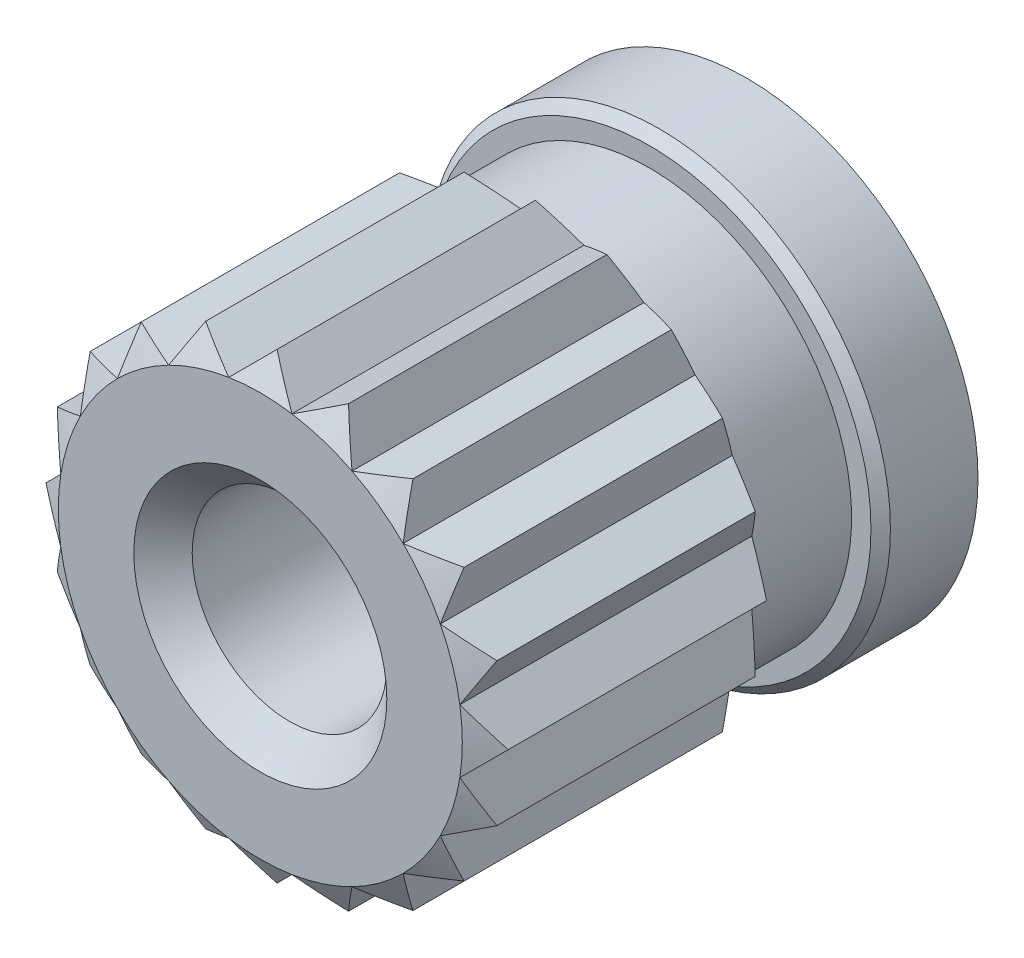
from build123d import *

# Parameters (mm, degrees)
BOSS_EXTRUDE1_DEPTH = 1.5
SKETCH2_OUTSIDE_W   = 18.614
SKETCH2_OUTSIDE_H   = 18.614
SKETCH2_OUTSIDE_R   = 2.075826116
CUT_EXTRUDE1_DEPTH  = 3
CUT_EXTRUDE1_TAPER  = 60
SKETCH3_R           = 2.375
BOSS_EXTRUDE2_DEPTH = 2
CUT_EXTRUDE3_START  = -1
SKETCH5_OUTSIDE_W   = 8.424
SKETCH5_OUTSIDE_H   = 8.424
SKETCH5_OUTSIDE_R   = 2.075826116
CUT_EXTRUDE3_DEPTH  = 1
CHAMFER1_SIZE       = 0.1
SKETCH6_R           = 1
CUT_EXTRUDE4_DEPTH  = 4
CHAMFER2_SIZE       = 0.3


with BuildPart() as part:
    # Sketch1 → Boss-Extrude1 (new body, symmetric)
    with BuildSketch(Plane.XY):
        Polygon((-0.324730748, 2.050269252), (0, 2.375), (0.324730748, 2.050269252), (0.733915362, 2.258759226), (0.942405336, 1.849574613), (1.395989974, 1.921415362), (1.467830723, 1.467830723), (1.921415362, 1.395989974), (1.849574613, 0.942405336), (2.258759226, 0.733915362), (2.050269252, 0.324730748), (2.375, 0), (2.050269252, -0.324730748), (2.258759226, -0.733915362), (1.849574613, -0.942405336), (1.921415362, -1.395989974), (1.467830723, -1.467830723), (1.395989974, -1.921415362), (0.942405336, -1.849574613), (0.733915362, -2.258759226), (0.324730748, -2.050269252), (0, -2.375), (-0.324730748, -2.050269252), (-0.733915362, -2.258759226), (-0.942405336, -1.849574613), (-1.395989974, -1.921415362), (-1.467830723, -1.467830723), (-1.921415362, -1.395989974), (-1.849574613, -0.942405336), (-2.258759226, -0.733915362), (-2.050269252, -0.324730748), (-2.375, 0), (-2.050269252, 0.324730748), (-2.258759226, 0.733915362), (-1.849574613, 0.942405336), (-1.921415362, 1.395989974), (-1.467830723, 1.467830723), (-1.395989974, 1.921415362), (-0.942405336, 1.849574613), (-0.733915362, 2.258759226), align=None)
    extrude(amount=BOSS_EXTRUDE1_DEPTH, both=True)

    # Sketch2 outside → Cut-Extrude1 (cut)
    with BuildSketch(Plane.XY.offset(1.5)):
        Rectangle(SKETCH2_OUTSIDE_W, SKETCH2_OUTSIDE_H)
        Circle(SKETCH2_OUTSIDE_R, mode=Mode.SUBTRACT)
    cut_extrude1 = extrude(amount=-CUT_EXTRUDE1_DEPTH, taper=CUT_EXTRUDE1_TAPER, mode=Mode.SUBTRACT)

    # Mirror1: Cut-Extrude1 across plane
    add(cut_extrude1.mirror(Plane.XY), mode=Mode.SUBTRACT)

    # Sketch3 → Boss-Extrude2 (add)
    with BuildSketch(Plane(origin=(0, 0, -1.5), x_dir=(-1, 0, 0), z_dir=(0, 0, -1))):
        Circle(SKETCH3_R)
    extrude(amount=BOSS_EXTRUDE2_DEPTH)

    # Sketch5 outside → Cut-Extrude3 (cut)
    with BuildSketch(Plane(origin=(0, 0, -3.5), x_dir=(-1, 0, 0), z_dir=(0, 0, -1)).offset(CUT_EXTRUDE3_START)):
        Rectangle(SKETCH5_OUTSIDE_W, SKETCH5_OUTSIDE_H)
        Circle(SKETCH5_OUTSIDE_R, mode=Mode.SUBTRACT)
    extrude(amount=-CUT_EXTRUDE3_DEPTH, mode=Mode.SUBTRACT)

    # Chamfer1
    chamfer1_edges = [part.edges().sort_by_distance(p)[0] for p in [
        (2.375, 0, -2.5),
    ]]
    chamfer(chamfer1_edges, length=CHAMFER1_SIZE)

    # Sketch6 → Cut-Extrude4 (cut)
    with BuildSketch(Plane.XY.offset(1.5)):
        Circle(SKETCH6_R)
    extrude(amount=-CUT_EXTRUDE4_DEPTH, mode=Mode.SUBTRACT)

    # Chamfer2
    chamfer2_edges = [part.edges().sort_by_distance(p)[0] for p in [
        (-1, 0, 1.5),
    ]]
    chamfer(chamfer2_edges, length=CHAMFER2_SIZE)


solid = part.part
